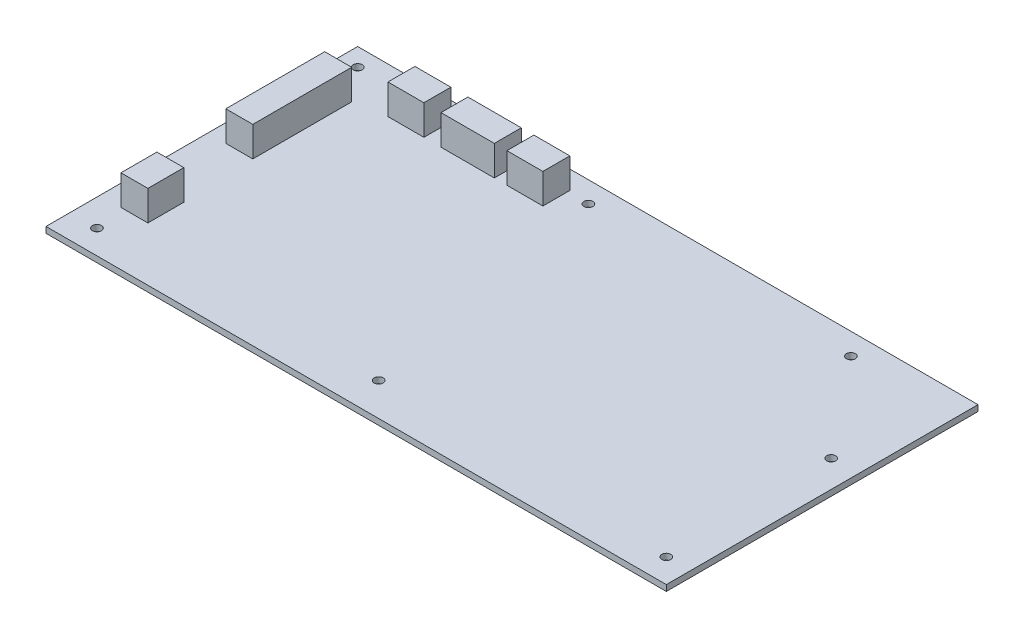
from build123d import *

# Parameters (mm, degrees)
ESQUISSE1_W             = 207
ESQUISSE1_H             = 104
BOSS_EXTRU_1_DEPTH      = 2
ESQUISSE3_R             = 1.5
ENL_V_MAT_EXTRU_1_DEPTH = 3
ESQUISSE4_W             = 9
ESQUISSE4_H             = 33
ESQUISSE4_H_2           = 12
ESQUISSE4_W_2           = 12
ESQUISSE4_H_3           = 9
ESQUISSE4_W_3           = 17.8
BOSS_EXTRU_2_DEPTH      = 10


with BuildPart() as part:
    # Esquisse1 → Boss.-Extru.1 (new body)
    with BuildSketch(Plane(origin=(0, 0, 0), x_dir=(1, 0, 0), z_dir=(0, 1, 0))):
        Rectangle(ESQUISSE1_W, ESQUISSE1_H)
    extrude(amount=BOSS_EXTRU_1_DEPTH)

    # Esquisse3 → Enlèv. mat.-Extru.1 (cut, through all)
    with BuildSketch(Plane(origin=(0, 2, 0), x_dir=(1, 0, 0), z_dir=(0, 1, 0))):
        with Locations((-97.5, 46)):
            Circle(ESQUISSE3_R)
        with Locations((-19.5, 45)):
            Circle(ESQUISSE3_R)
        with Locations((68.3, 44.8)):
            Circle(ESQUISSE3_R)
        with Locations((94.5, 12)):
            Circle(ESQUISSE3_R)
        with Locations((95.5, -44)):
            Circle(ESQUISSE3_R)
        with Locations((-3.5, -41)):
            Circle(ESQUISSE3_R)
        with Locations((-94.5, -44)):
            Circle(ESQUISSE3_R)
    extrude(amount=-ENL_V_MAT_EXTRU_1_DEPTH, mode=Mode.SUBTRACT)

    # Esquisse4 → Boss.-Extru.2 (add)
    with BuildSketch(Plane(origin=(0, 2, 0), x_dir=(1, 0, 0), z_dir=(0, 1, 0))):
        with Locations((-93, 18.5)):
            Rectangle(ESQUISSE4_W, ESQUISSE4_H)
        with Locations((-92, -28)):
            Rectangle(ESQUISSE4_W, ESQUISSE4_H_2)
        with Locations((-72.2, 41.3)):
            Rectangle(ESQUISSE4_W_2, ESQUISSE4_H_3)
        with Locations((-51.6, 41.3)):
            Rectangle(ESQUISSE4_W_3, ESQUISSE4_H_3)
        with Locations((-32.5, 41.3)):
            Rectangle(ESQUISSE4_W_2, ESQUISSE4_H_3)
    extrude(amount=BOSS_EXTRU_2_DEPTH)


solid = part.part
